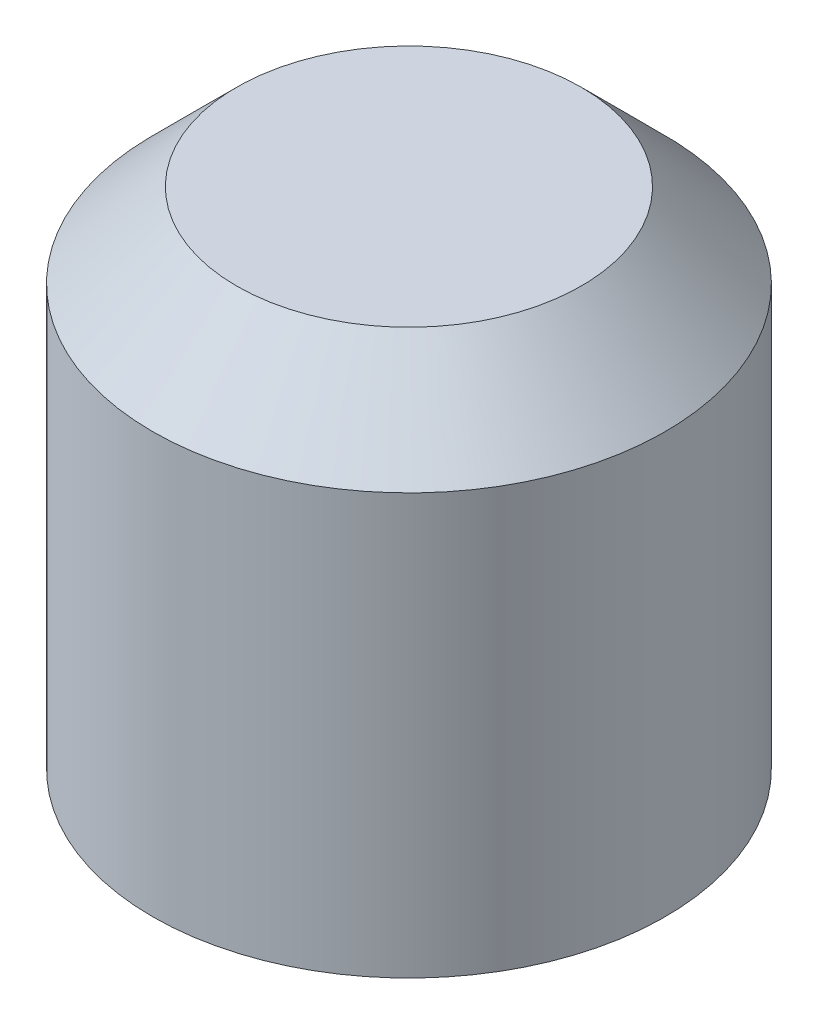
from build123d import *

# Parameters (mm, degrees)
SKETCH2_R           = 1.525
BOSS_EXTRUDE1_DEPTH = 3
CHAMFER1_SIZE       = 0.5


with BuildPart() as part:
    # Sketch2 → Boss-Extrude1 (new body)
    with BuildSketch(Plane(origin=(0, 0, 0), x_dir=(1, 0, 0), z_dir=(0, 1, 0))):
        Circle(SKETCH2_R)
    extrude(amount=BOSS_EXTRUDE1_DEPTH)

    # Chamfer1
    chamfer1_edges = [part.edges().sort_by_distance(p)[0] for p in [
        (-1.525, 3, 0),
    ]]
    chamfer(chamfer1_edges, length=CHAMFER1_SIZE)


solid = part.part
